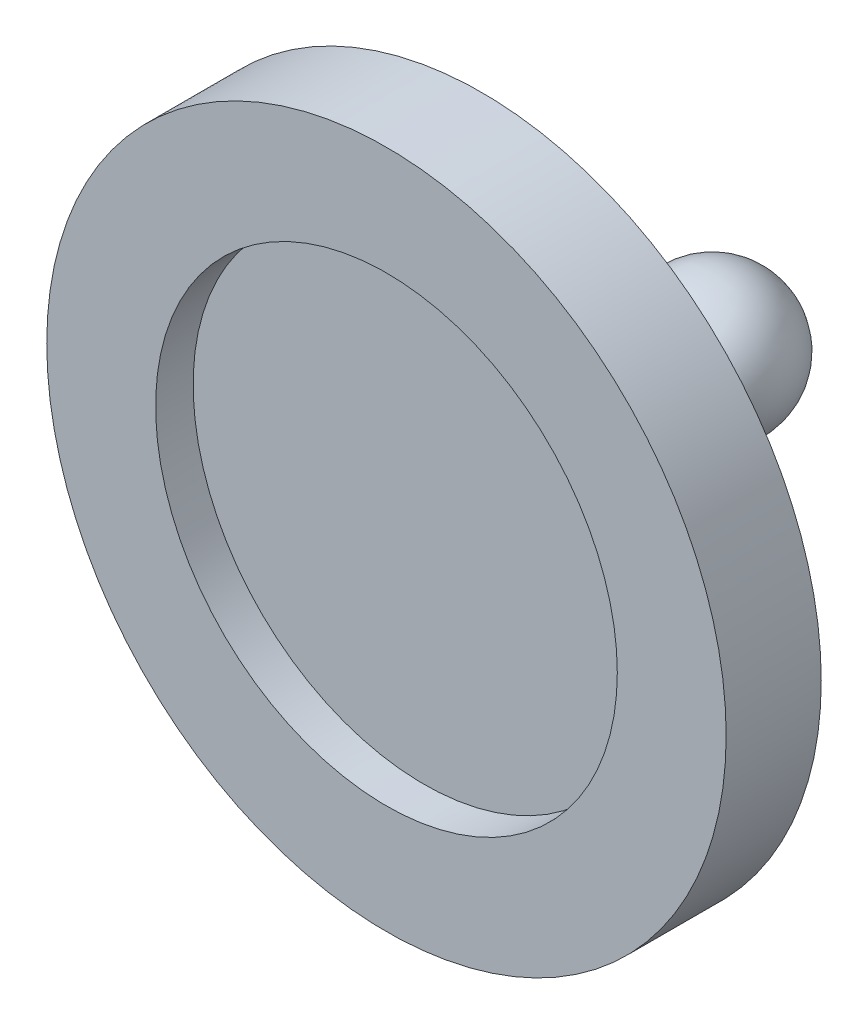
from build123d import *


with BuildPart() as part:
    # Sketch2 → Revolve1 (revolve)
    with BuildSketch(Plane(origin=(0, 0, 0), x_dir=(1, 0, 0), z_dir=(0, 1, 0))):
        with BuildLine():
            Line((2.286925107, 17.883208285), (10.602093534, 9.568039858))
            Line((10.602093534, 9.568039858), (15.602093534, 9.568039858))
            Line((15.602093534, 9.568039858), (15.602093534, 5.20121338))
            Line((15.602093534, 5.20121338), (10.602093534, 5.20121338))
            Line((10.602093534, 5.20121338), (10.602093534, 6.924075642))
            Line((10.602093534, 6.924075642), (0, 6.924075642))
            Line((0, 6.924075642), (0, 23.404333894))
            ThreePointArc((0, 23.404333894), (2.988011648, 21.407808341), (2.286925107, 17.883208285))
        make_face()
    revolve(axis=Axis((0, 0, 0), (0, 0, -1)))


solid = part.part
